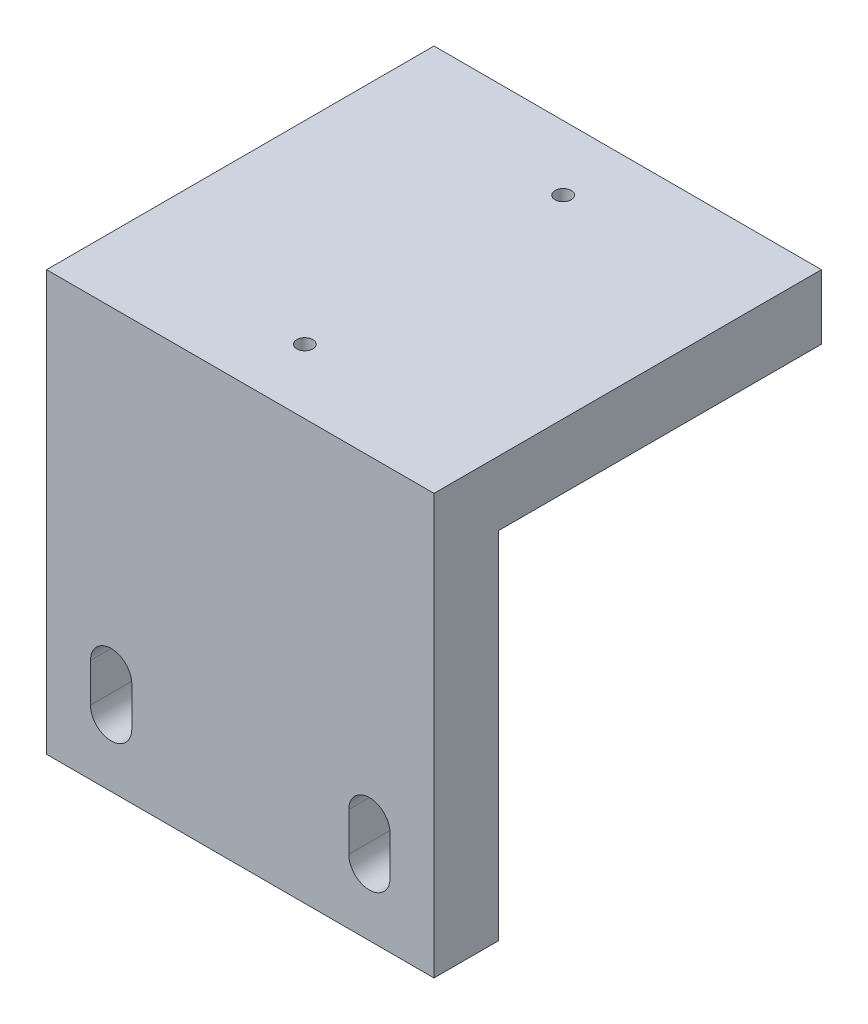
from build123d import *

# Parameters (mm, degrees)
SKETCH_1_W             = 60
SKETCH_1_H             = 65
EXTRUDE_1_DEPTH        = 60
SKETCH_2_W             = 60
SKETCH_2_H             = 55
CUT_EXTRUDE_1_DEPTH    = 50
CUT_EXTRUDE_2_DEPTH    = 61
HOLE_WIZARD_M3_1_D     = 2.5
HOLE_WIZARD_M3_1_DEPTH = 7.5
HOLE_WIZARD_M3_1_TIP   = 0.751075774


with BuildPart() as part:
    # 草图1 → 凸台-拉伸1 (new body)
    with BuildSketch(Plane.XY):
        Rectangle(SKETCH_1_W, SKETCH_1_H)
    extrude(amount=EXTRUDE_1_DEPTH)

    # 草图2 → 切除-拉伸1 (cut)
    with BuildSketch(Plane(origin=(0, 0, 0), x_dir=(-1, 0, 0), z_dir=(0, 0, -1))):
        with Locations((0, -5)):
            Rectangle(SKETCH_2_W, SKETCH_2_H)
    extrude(amount=-CUT_EXTRUDE_1_DEPTH, mode=Mode.SUBTRACT)

    # 草图3 → 切除-拉伸2 (cut, through all)
    with BuildSketch(Plane.XY.offset(60)):
        with BuildLine():
            Line((-23.2, -22.5), (-23.2, -16.5))
            ThreePointArc((-23.2, -16.5), (-20, -13.3), (-16.8, -16.5))
            Line((-16.8, -16.5), (-16.8, -22.5))
            ThreePointArc((-16.8, -22.5), (-20, -25.7), (-23.2, -22.5))
        make_face()
        with BuildLine():
            Line((23.2, -22.5), (23.2, -16.5))
            ThreePointArc((23.2, -16.5), (20, -13.3), (16.8, -16.5))
            Line((16.8, -16.5), (16.8, -22.5))
            ThreePointArc((16.8, -22.5), (20, -25.7), (23.2, -22.5))
        make_face()
    extrude(amount=-CUT_EXTRUDE_2_DEPTH, mode=Mode.SUBTRACT)

    # M3 螺纹孔1
    with Locations(Plane(origin=(0, 32.5, 10), x_dir=(1, 0, 0), z_dir=(0, 1, 0))):
        with Locations((0, 0), (0, -40)):
            Hole(HOLE_WIZARD_M3_1_D / 2, depth=HOLE_WIZARD_M3_1_DEPTH)
            with Locations((0, 0, -(HOLE_WIZARD_M3_1_DEPTH + HOLE_WIZARD_M3_1_TIP / 2))):  # 118° drill point
                Cone(0, HOLE_WIZARD_M3_1_D / 2, HOLE_WIZARD_M3_1_TIP, mode=Mode.SUBTRACT)


solid = part.part
